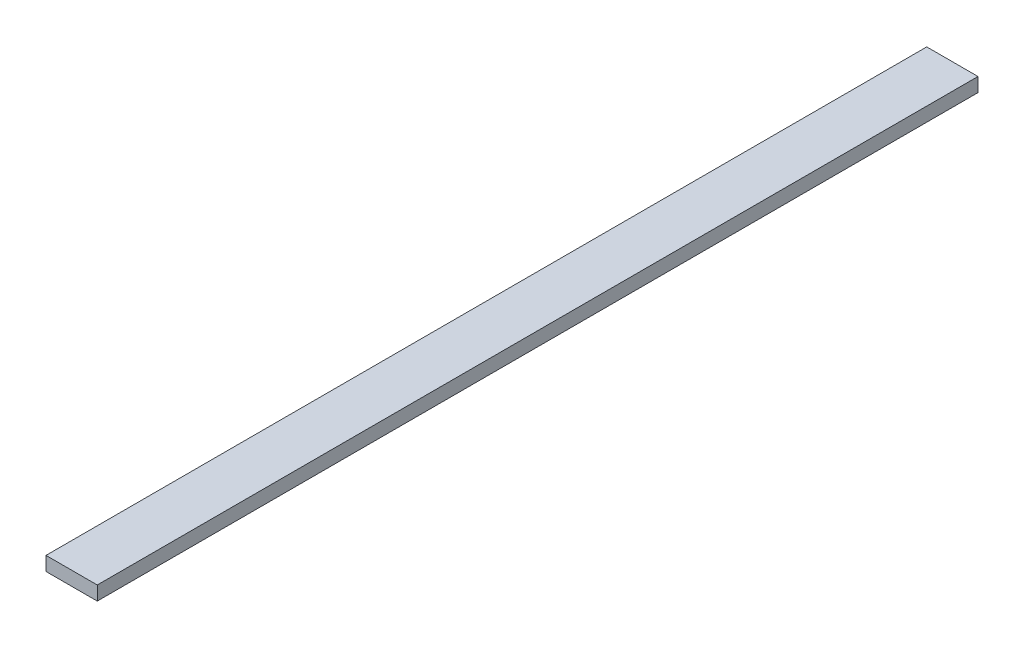
from build123d import *

# Parameters (mm, degrees)
SKETCH1_W           = 139.7
SKETCH1_H           = 38.1
BOSS_EXTRUDE1_DEPTH = 2438.4
SKETCH2_W           = 139.7
SKETCH2_H           = 38.1
CUT_EXTRUDE1_DEPTH  = 39.1


with BuildPart() as part:
    # Sketch1 → Boss-Extrude1 (new body)
    with BuildSketch(Plane.XY):
        with Locations((69.85, 19.05)):
            Rectangle(SKETCH1_W, SKETCH1_H)
    extrude(amount=BOSS_EXTRUDE1_DEPTH)

    # Sketch2 → Cut-Extrude1 (cut, through all)
    with BuildSketch(Plane(origin=(0, 38.1, 0), x_dir=(1, 0, 0), z_dir=(0, 1, 0))):
        with Locations((69.85, -2419.35)):
            Rectangle(SKETCH2_W, SKETCH2_H)
    extrude(amount=-CUT_EXTRUDE1_DEPTH, mode=Mode.SUBTRACT)


solid = part.part
